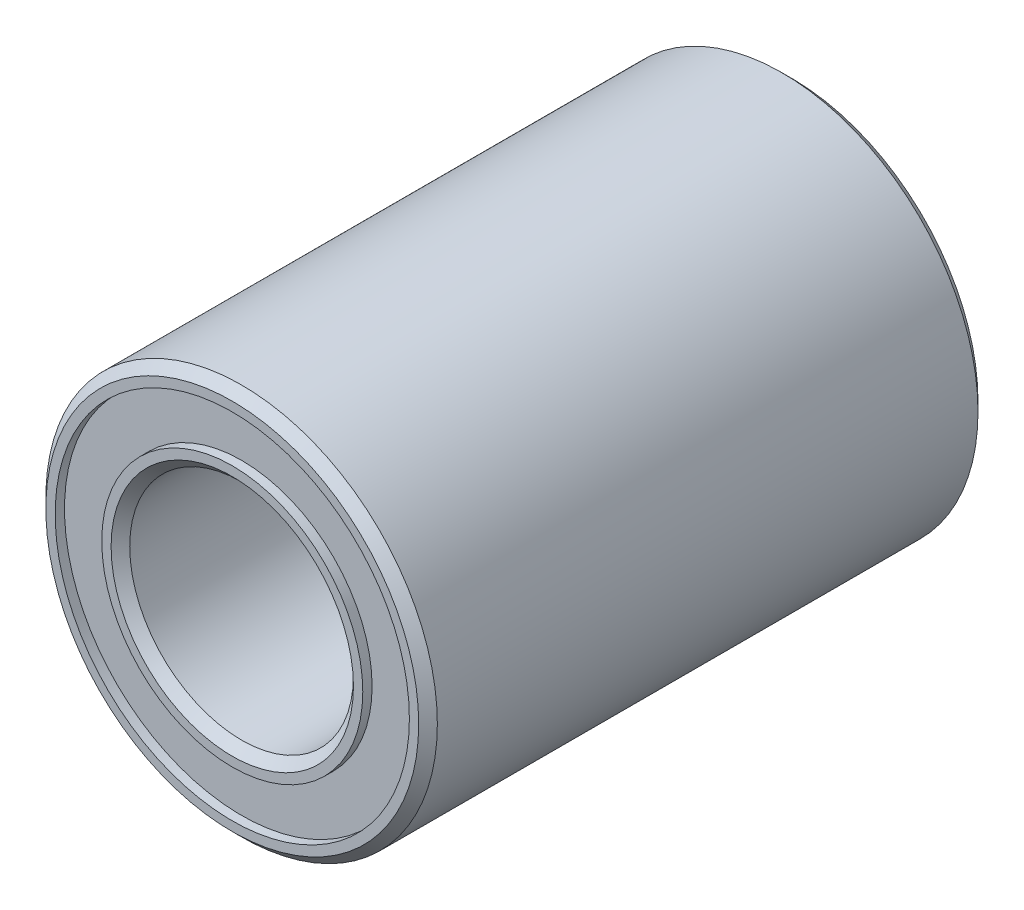
from build123d import *

# Parameters (mm, degrees)
SKETCH1_R           = 10.5
SKETCH1_R_2         = 6
BOSS_EXTRUDE1_DEPTH = 30
SKETCH2_R           = 9.5
SKETCH2_R_2         = 7
CUT_EXTRUDE1_DEPTH  = 0.5
SKETCH3_R           = 9.5
SKETCH3_R_2         = 7
CUT_EXTRUDE2_DEPTH  = 0.5
CHAMFER1_SIZE       = 0.5


with BuildPart() as part:
    # Sketch1 → Boss-Extrude1 (new body)
    with BuildSketch(Plane.XY):
        Circle(SKETCH1_R)
        Circle(SKETCH1_R_2, mode=Mode.SUBTRACT)
    extrude(amount=BOSS_EXTRUDE1_DEPTH)

    # Sketch2 → Cut-Extrude1 (cut)
    with BuildSketch(Plane.XY.offset(30)):
        Circle(SKETCH2_R)
        Circle(SKETCH2_R_2, mode=Mode.SUBTRACT)
    extrude(amount=-CUT_EXTRUDE1_DEPTH, mode=Mode.SUBTRACT)

    # Sketch3 → Cut-Extrude2 (cut)
    with BuildSketch(Plane(origin=(0, 0, 0), x_dir=(-1, 0, 0), z_dir=(0, 0, -1))):
        Circle(SKETCH3_R)
        Circle(SKETCH3_R_2, mode=Mode.SUBTRACT)
    extrude(amount=-CUT_EXTRUDE2_DEPTH, mode=Mode.SUBTRACT)

    # Chamfer1
    chamfer1_edges = [part.edges().sort_by_distance(p)[0] for p in [
        (-10.5, 0, 0),
        (-10.5, 0, 30),
        (-6, 0, 0),
        (-6, 0, 30),
    ]]
    chamfer(chamfer1_edges, length=CHAMFER1_SIZE)


solid = part.part
